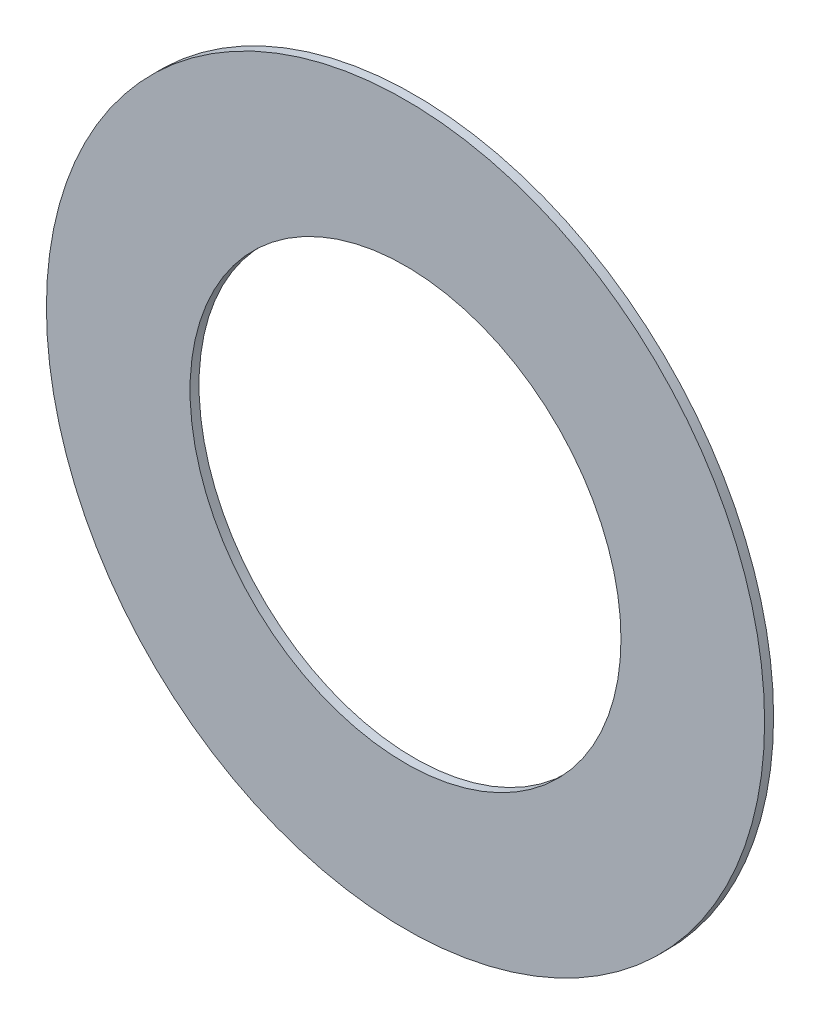
from build123d import *

# Parameters (mm, degrees)
SKETCH1_R           = 127
SKETCH1_R_2         = 76.2
BOSS_EXTRUDE1_DEPTH = 3.175


with BuildPart() as part:
    # Sketch1 → Boss-Extrude1 (new body)
    with BuildSketch(Plane.XY):
        Circle(SKETCH1_R)
        Circle(SKETCH1_R_2, mode=Mode.SUBTRACT)
    extrude(amount=BOSS_EXTRUDE1_DEPTH)


solid = part.part
